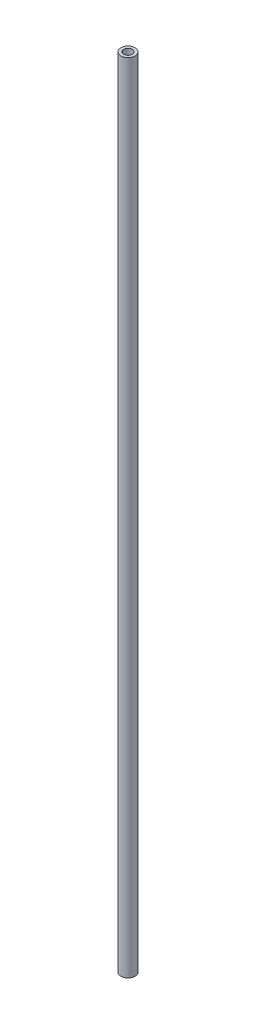
from build123d import *

# Parameters (mm, degrees)
SKETCH2_R           = 2.5
SKETCH2_R_2         = 1.5
BOSS_EXTRUDE3_DEPTH = 140


with BuildPart() as part:
    # Sketch2 → Boss-Extrude3 (new body, symmetric)
    with BuildSketch(Plane(origin=(0, 0, 0), x_dir=(1, 0, 0), z_dir=(0, 1, 0))):
        Circle(SKETCH2_R)
        Circle(SKETCH2_R_2, mode=Mode.SUBTRACT)
    extrude(amount=BOSS_EXTRUDE3_DEPTH, both=True)


solid = part.part
